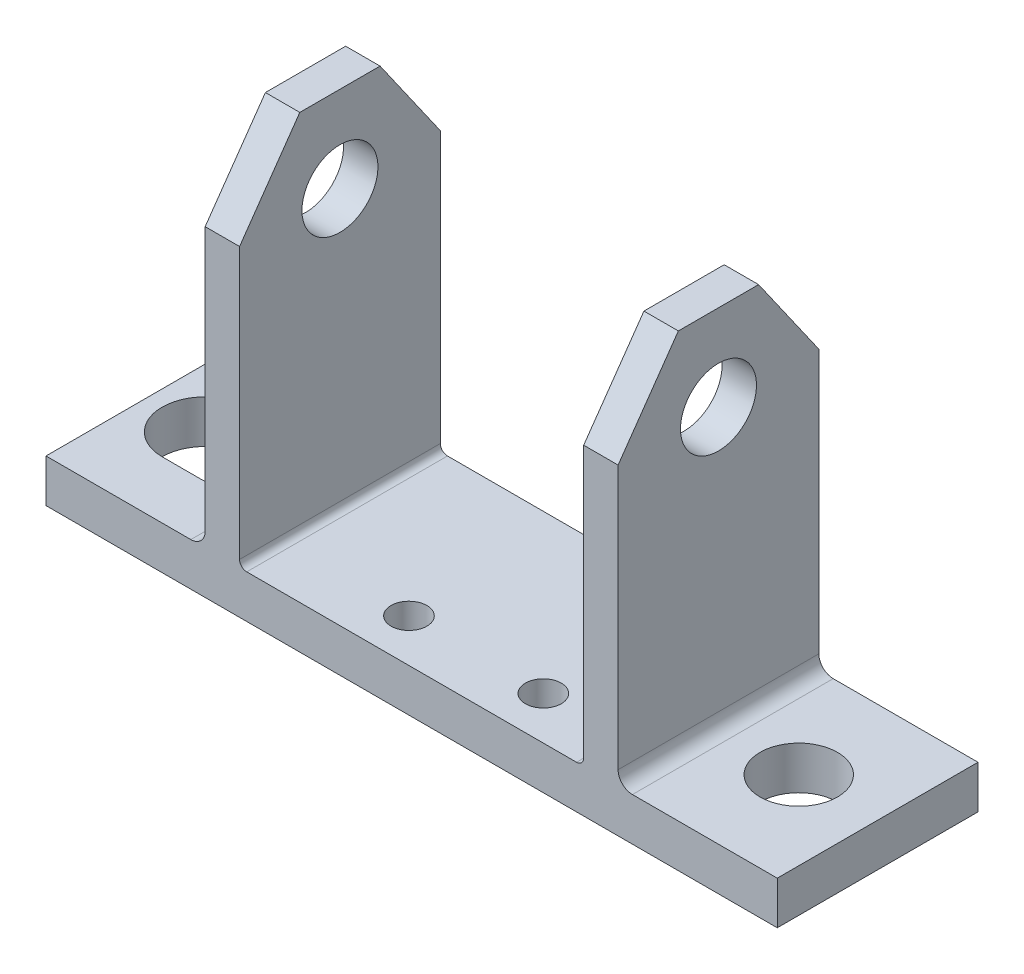
from build123d import *

# Parameters (mm, degrees)
SKETCH1_W           = 51
SKETCH1_H           = 14
SKETCH1_R           = 2.7
BOSS_EXTRUDE1_DEPTH = 3
SKETCH2_W           = 2.4
SKETCH2_H           = 14
BOSS_EXTRUDE2_DEPTH = 25.4
CUT_EXTRUDE1_REACH  = 5
SKETCH3_R           = 1.25
SKETCH4_R           = 2.65
CUT_EXTRUDE2_DEPTH  = 40.9
CUT_EXTRUDE3_DEPTH  = 40.9
FILLET1_R           = 1
FILLET2_R           = 0.5


with BuildPart() as part:
    # Sketch1 → Boss-Extrude1 (new body)
    with BuildSketch(Plane(origin=(0, 0, 0), x_dir=(1, 0, 0), z_dir=(0, 1, 0))):
        with Locations((25.5, 7)):
            Rectangle(SKETCH1_W, SKETCH1_H)
        with Locations((45.5, 7)):
            Circle(SKETCH1_R, mode=Mode.SUBTRACT)
        with BuildLine():
            Line((4.1, 10), (6.9, 10))
            ThreePointArc((6.9, 10), (9.9, 7), (6.9, 4))
            Line((6.9, 4), (4.1, 4))
            ThreePointArc((4.1, 4), (1.1, 7), (4.1, 10))
        make_face(mode=Mode.SUBTRACT)
    extrude(amount=BOSS_EXTRUDE1_DEPTH)

    # Sketch2 → Boss-Extrude2 (add)
    with BuildSketch(Plane(origin=(0, 3, 0), x_dir=(1, 0, 0), z_dir=(0, 1, 0))):
        with Locations((12.3, 7)):
            Rectangle(SKETCH2_W, SKETCH2_H)
        with Locations((38.7, 7)):
            Rectangle(SKETCH2_W, SKETCH2_H)
    extrude(amount=BOSS_EXTRUDE2_DEPTH)

    # Sketch3 → Cut-Extrude1 (cut, up to next)
    with BuildSketch(Plane(origin=(0, 3, 0), x_dir=(1, 0, 0), z_dir=(0, 1, 0)), mode=Mode.PRIVATE) as cut_extrude1_sk1:
        with Locations((22.314, 3)):
            Circle(SKETCH3_R)
    cut_extrude1_tool1 = extrude(cut_extrude1_sk1.sketch, amount=-CUT_EXTRUDE1_REACH, mode=Mode.PRIVATE) & part.part
    add(cut_extrude1_tool1.solids().sort_by_distance((22.314, 3, -3))[0], mode=Mode.SUBTRACT)
    # Sketch3 → Cut-Extrude1 (cut, up to next)
    with BuildSketch(Plane(origin=(0, 3, 0), x_dir=(1, 0, 0), z_dir=(0, 1, 0)), mode=Mode.PRIVATE) as cut_extrude1_sk2:
        with Locations((31.686, 3)):
            Circle(SKETCH3_R)
    cut_extrude1_tool2 = extrude(cut_extrude1_sk2.sketch, amount=-CUT_EXTRUDE1_REACH, mode=Mode.PRIVATE) & part.part
    add(cut_extrude1_tool2.solids().sort_by_distance((31.686, 3, -3))[0], mode=Mode.SUBTRACT)

    # Sketch4 → Cut-Extrude2 (cut, through all)
    with BuildSketch(Plane.ZY.offset(-11.1)):
        with Locations((-7, 22.4)):
            Circle(SKETCH4_R)
    extrude(amount=-CUT_EXTRUDE2_DEPTH, mode=Mode.SUBTRACT)

    # Sketch5 → Cut-Extrude3 (cut, through all)
    with BuildSketch(Plane.ZY.offset(-11.1)):
        Polygon((-14, 22.4), (-9.798754771, 28.4), (-14, 28.4), align=None)
        Polygon((0, 22.4), (-4.201245229, 28.4), (0, 28.4), align=None)
    extrude(amount=-CUT_EXTRUDE3_DEPTH, mode=Mode.SUBTRACT)

    # Fillet1
    fillet1_edges = [part.edges().sort_by_distance(p)[0] for p in [
        (39.9, 3, -7),
        (11.1, 3, -7),
    ]]
    fillet(fillet1_edges, radius=FILLET1_R)

    # Fillet2
    fillet2_edges = [part.edges().sort_by_distance(p)[0] for p in [
        (37.5, 3, -7),
        (13.5, 3, -7),
    ]]
    fillet(fillet2_edges, radius=FILLET2_R)


solid = part.part
